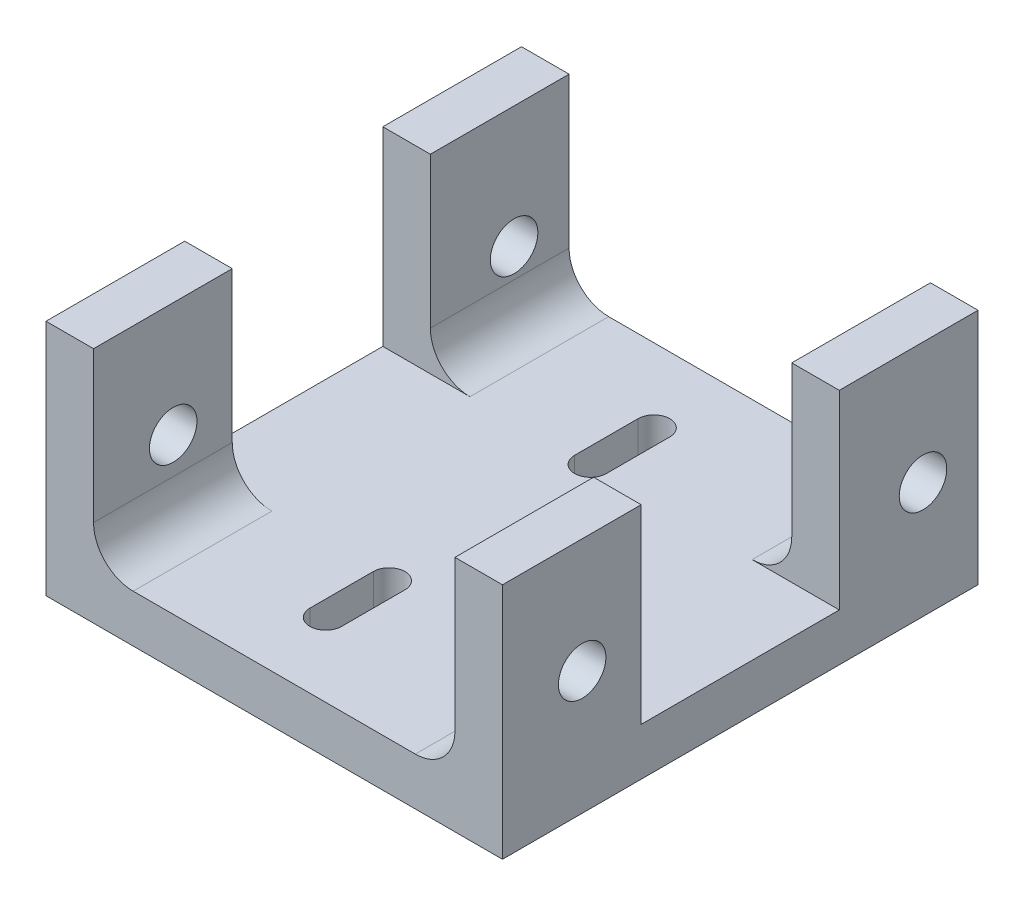
from build123d import *

# Parameters (mm, degrees)
EXTRUDE_1_DEPTH     = 30
SKETCH_2_W          = 12.5
SKETCH_2_H          = 12
CUT_EXTRUDE_1_DEPTH = 28.8
CUT_EXTRUDE_2_REACH = 5
MM_PRESS_1_D        = 3
FILLET_1_R          = 2.5


with BuildPart() as part:
    # 草图1 → 凸台-拉伸1 (new body)
    with BuildSketch(Plane.XY):
        Polygon((0, 0), (0, 12), (-3, 12), (-3, -3), (25.8, -3), (25.8, 12), (22.8, 12), (22.8, 0), align=None)
    extrude(amount=EXTRUDE_1_DEPTH)

    # 草图2 → 切除-拉伸1 (cut)
    with BuildSketch(Plane(origin=(25.8, 0, 0), x_dir=(0, 0, -1), z_dir=(1, 0, 0))):
        with Locations((-15, 6)):
            Rectangle(SKETCH_2_W, SKETCH_2_H)
    extrude(amount=-CUT_EXTRUDE_1_DEPTH, mode=Mode.SUBTRACT)

    # 草图3 → 切除-拉伸2 (cut, up to next)
    with BuildSketch(Plane(origin=(0, 0, 0), x_dir=(1, 0, 0), z_dir=(0, 1, 0)), mode=Mode.PRIVATE) as cut_extrude_2_sk1:
        with BuildLine():
            Line((11, -4.647050091), (11, -8.647050091))
            ThreePointArc((11, -8.647050091), (10, -9.647050091), (9, -8.647050091))
            Line((9, -8.647050091), (9, -4.647050091))
            ThreePointArc((9, -4.647050091), (10, -3.647050091), (11, -4.647050091))
        make_face()
    cut_extrude_2_tool1 = extrude(cut_extrude_2_sk1.sketch, amount=-CUT_EXTRUDE_2_REACH, mode=Mode.PRIVATE) & part.part
    add(cut_extrude_2_tool1.solids().sort_by_distance((10, 0, 6.64705))[0], mode=Mode.SUBTRACT)
    # 草图3 → 切除-拉伸2 (cut, up to next)
    with BuildSketch(Plane(origin=(0, 0, 0), x_dir=(1, 0, 0), z_dir=(0, 1, 0)), mode=Mode.PRIVATE) as cut_extrude_2_sk2:
        with BuildLine():
            Line((11, -25.352949909), (11, -21.352949909))
            ThreePointArc((11, -21.352949909), (10, -20.352949909), (9, -21.352949909))
            Line((9, -21.352949909), (9, -25.352949909))
            ThreePointArc((9, -25.352949909), (10, -26.352949909), (11, -25.352949909))
        make_face()
    cut_extrude_2_tool2 = extrude(cut_extrude_2_sk2.sketch, amount=-CUT_EXTRUDE_2_REACH, mode=Mode.PRIVATE) & part.part
    add(cut_extrude_2_tool2.solids().sort_by_distance((10, 0, 23.35295))[0], mode=Mode.SUBTRACT)

    # 大小mm Press 暗销孔1 (through all)
    with Locations(Plane(origin=(-3, 140.185527162, 21.233815274), x_dir=(0, -0.020968354, -0.99978014), z_dir=(-1, 0, 0))):
        with Locations((20.608818994, 135.452556109), (-0.900285243, 135.452556109)):
            Hole(MM_PRESS_1_D / 2)

    # 圆角1
    fillet_1_edges = [part.edges().sort_by_distance(p)[0] for p in [
        (22.8, 0, 25.625),
        (0, 0, 25.625),
        (22.8, 0, 4.375),
        (0, 0, 4.375),
    ]]
    fillet(fillet_1_edges, radius=FILLET_1_R)


solid = part.part
